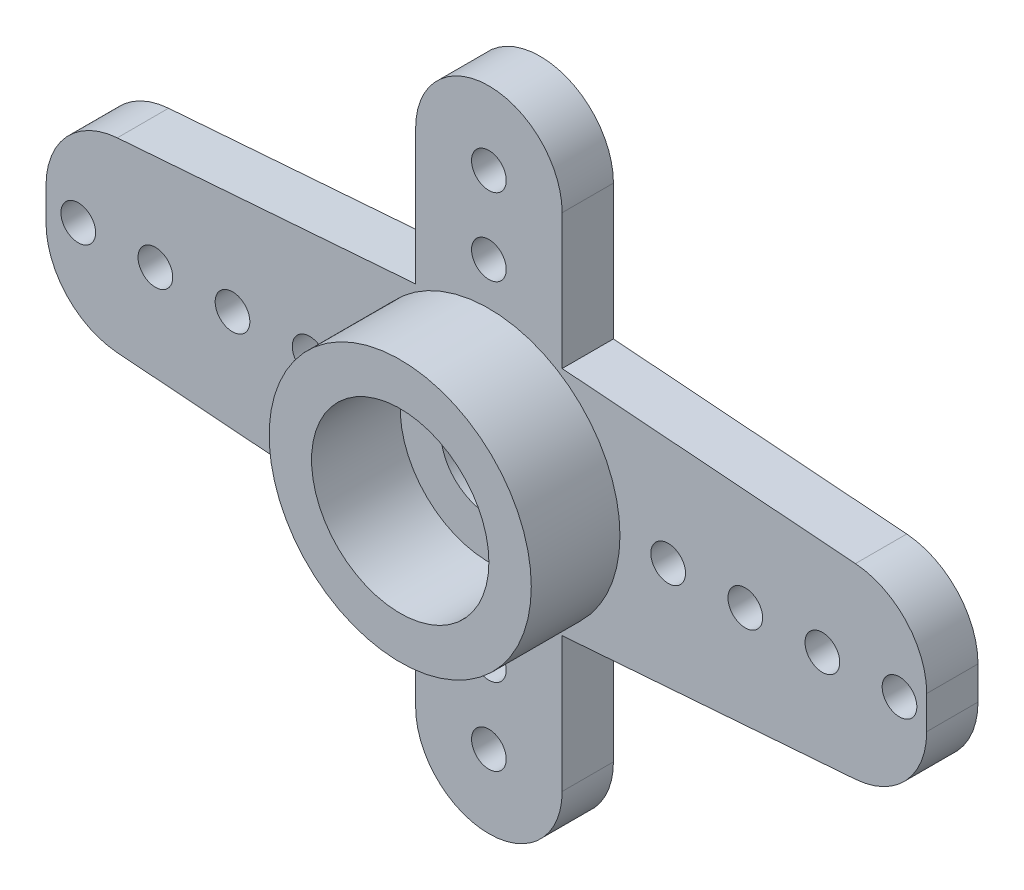
from build123d import *

# Parameters (mm, degrees)
AUFSATZ_LINEAR_AUSTRAGEN1_DEPTH      = 1.33
SKIZZE2_R                            = 3.4
SKIZZE2_R_2                          = 2.3
AUFSATZ_LINEAR_AUSTRAGEN2_DEPTH      = 2.3
AUFSATZ_LINEAR_AUSTRAGEN2_DEPTH_BACK = 1.33
SKIZZE3_R                            = 1.25
SCHNITT_LINEAR_AUSTRAGEN1_DEPTH      = 2.33
SKIZZE4_R                            = 2.35
SCHNITT_LINEAR_AUSTRAGEN2_DEPTH      = 1.1
SKIZZE5_R                            = 0.45
SCHNITT_LINEAR_AUSTRAGEN3_DEPTH      = 2.33
SKIZZE7_W                            = 8.843573308
SKIZZE7_H                            = 7.939116947
SKIZZE7_W_2                          = 8.543023068
SKIZZE7_H_2                          = 6.617341639
SCHNITT_LINEAR_AUSTRAGEN4_DEPTH      = 1.33
VERRUNDUNG1_R                        = 2


with BuildPart() as part:
    # Skizze1 → Aufsatz-Linear austragen1 (new body)
    with BuildSketch(Plane.XY):
        with BuildLine():
            Line((-16.79191458, 1.869621687), (-1.9, 3))
            Line((-1.9, 3), (-1.9, 6.5))
            ThreePointArc((-1.9, 6.5), (0, 8.4), (1.9, 6.5))
            Line((1.9, 6.5), (1.9, 3))
            Line((1.9, 3), (16.79191458, 1.869621687))
            ThreePointArc((16.79191458, 1.869621687), (18.525, 0), (16.79191458, -1.869621687))
            Line((16.79191458, -1.869621687), (1.9, -3))
            Line((1.9, -3), (1.9, -6.5))
            ThreePointArc((1.9, -6.5), (0, -8.4), (-1.9, -6.5))
            Line((-1.9, -6.5), (-1.9, -3))
            Line((-1.9, -3), (-16.79191458, -1.869621687))
            ThreePointArc((-16.79191458, -1.869621687), (-18.525, 0), (-16.79191458, 1.869621687))
        make_face()
    extrude(amount=AUFSATZ_LINEAR_AUSTRAGEN1_DEPTH)

    # Skizze2 → Aufsatz-Linear austragen2 (add, two sides)
    with BuildSketch(Plane.XY.offset(1.33)) as aufsatz_linear_austragen2_sk:
        Circle(SKIZZE2_R)
        Circle(SKIZZE2_R_2, mode=Mode.SUBTRACT)
    extrude(amount=AUFSATZ_LINEAR_AUSTRAGEN2_DEPTH)
    extrude(aufsatz_linear_austragen2_sk.sketch, amount=-AUFSATZ_LINEAR_AUSTRAGEN2_DEPTH_BACK)

    # Skizze3 → Schnitt-Linear austragen1 (cut, through all)
    with BuildSketch(Plane.XY.offset(1.33)):
        Circle(SKIZZE3_R)
    extrude(amount=-SCHNITT_LINEAR_AUSTRAGEN1_DEPTH, mode=Mode.SUBTRACT)

    # Skizze4 → Schnitt-Linear austragen2 (cut)
    with BuildSketch(Plane(origin=(0, 0, 0), x_dir=(-1, 0, 0), z_dir=(0, 0, -1))):
        Circle(SKIZZE4_R)
    extrude(amount=-SCHNITT_LINEAR_AUSTRAGEN2_DEPTH, mode=Mode.SUBTRACT)

    # Skizze5 → Schnitt-Linear austragen3 (cut, through all)
    with BuildSketch(Plane.XY.offset(1.33)):
        with Locations((0, 6.5)):
            Circle(SKIZZE5_R)
        with Locations((-16.65, 0)):
            Circle(SKIZZE5_R)
        with Locations((0, 4.5)):
            Circle(SKIZZE5_R)
        with Locations((-14.65, 0)):
            Circle(SKIZZE5_R)
        with Locations((-12.65, 0)):
            Circle(SKIZZE5_R)
        with Locations((-10.65, 0)):
            Circle(SKIZZE5_R)
        with Locations((-8.65, 0)):
            Circle(SKIZZE5_R)
        with Locations((-6.65, 0)):
            Circle(SKIZZE5_R)
        with Locations((-4.65, 0)):
            Circle(SKIZZE5_R)
        with Locations((0, -4.5)):
            Circle(SKIZZE5_R)
        with Locations((0, -6.5)):
            Circle(SKIZZE5_R)
        with Locations((4.65, 0)):
            Circle(SKIZZE5_R)
        with Locations((6.65, 0)):
            Circle(SKIZZE5_R)
        with Locations((8.65, 0)):
            Circle(SKIZZE5_R)
        with Locations((10.65, 0)):
            Circle(SKIZZE5_R)
        with Locations((12.65, 0)):
            Circle(SKIZZE5_R)
        with Locations((14.65, 0)):
            Circle(SKIZZE5_R)
        with Locations((16.65, 0)):
            Circle(SKIZZE5_R)
    extrude(amount=-SCHNITT_LINEAR_AUSTRAGEN3_DEPTH, mode=Mode.SUBTRACT)

    # Skizze7 → Schnitt-Linear austragen4 (cut)
    with BuildSketch(Plane(origin=(0, 0, 0), x_dir=(-1, 0, 0), z_dir=(0, 0, -1))):
        with Locations((-15.777738742, 0.234488686)):
            Rectangle(SKIZZE7_W, SKIZZE7_H)
        with Locations((15.758609631, 0.140049559)):
            Rectangle(SKIZZE7_W_2, SKIZZE7_H_2)
    extrude(amount=-SCHNITT_LINEAR_AUSTRAGEN4_DEPTH, mode=Mode.SUBTRACT)

    # Verrundung1
    verrundung1_edges = [part.edges().sort_by_distance(p)[0] for p in [
        (11.355952088, -2.282241171, 0.665),
        (11.355952088, 2.282241171, 0.665),
        (-11.487098097, -2.272286467, 0.665),
        (-11.487098097, 2.272286467, 0.665),
    ]]
    fillet(verrundung1_edges, radius=VERRUNDUNG1_R)


solid = part.part
